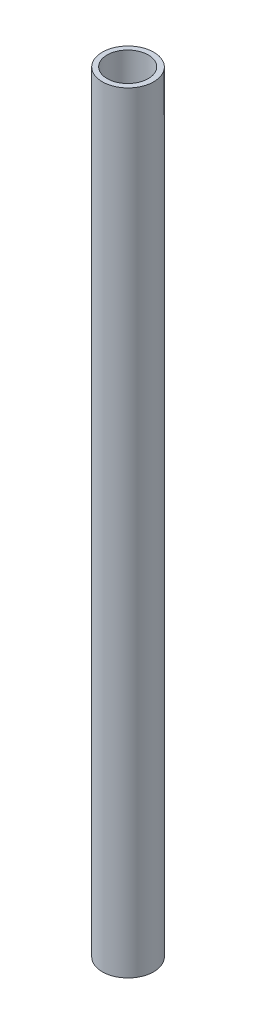
from build123d import *

# Parameters (mm, degrees)
SKETCH1_W          = 5
SKETCH1_H          = 150
SKETCH2_R          = 4
CUT_EXTRUDE1_DEPTH = 151.024531183


with BuildPart() as part:
    # Sketch1 → Revolve1 (revolve)
    with BuildSketch(Plane.XY):
        with Locations((2.5, 75)):
            Rectangle(SKETCH1_W, SKETCH1_H)
    revolve(axis=Axis((0, 0, 0), (0, 1, 0)))

    # Sketch2 → Cut-Extrude1 (cut, through all)
    with BuildSketch(Plane(origin=(5, 150, 0), x_dir=(0.999996875, -0.002499993, 0), z_dir=(0.002499993, 0.999996875, 0))):
        with Locations((-5.062484107, 0)):
            Circle(SKETCH2_R)
    extrude(amount=-CUT_EXTRUDE1_DEPTH, mode=Mode.SUBTRACT)


solid = part.part
